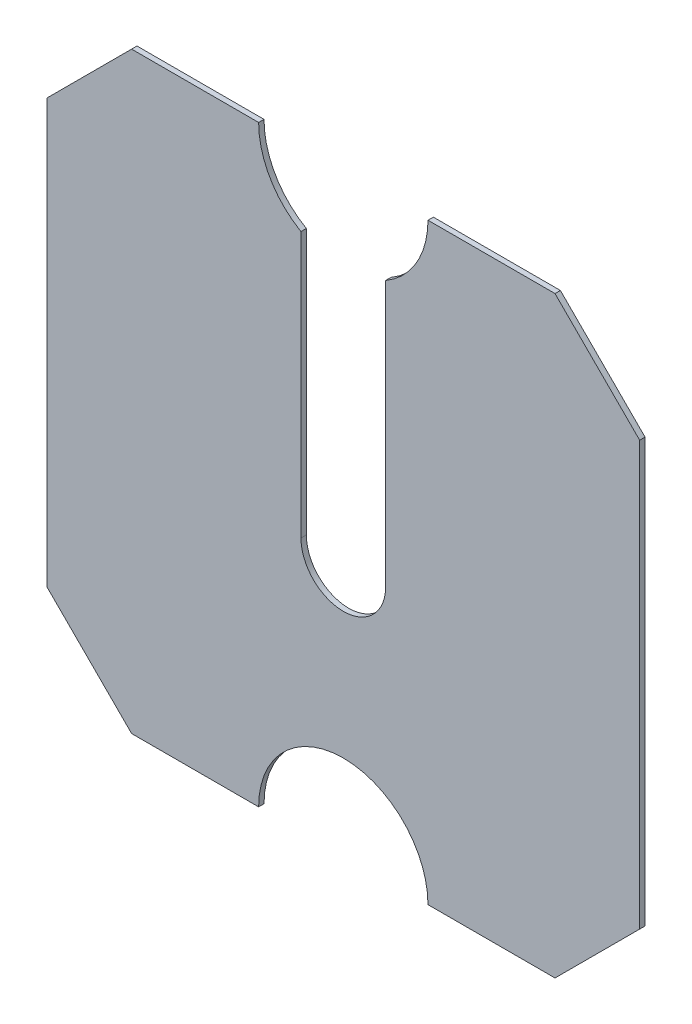
from build123d import *

# Parameters (mm, degrees)
BOSS_EXTRUDE1_DEPTH = 3.175
CUT_EXTRUDE1_DEPTH  = 3.175


with BuildPart() as part:
    # Sketch1 → Boss-Extrude1 (new body)
    with BuildSketch(Plane.XY):
        with BuildLine():
            Line((175, 300), (175, 50))
            Line((175, 50), (125, 0))
            Line((125, 0), (50, 0))
            ThreePointArc((50, 0), (0, 50), (-50, 0))
            Line((-50, 0), (-125, 0))
            Line((-125, 0), (-175, 50))
            Line((-175, 50), (-175, 300))
            Line((-175, 300), (-125, 350))
            Line((-125, 350), (-50, 350))
            ThreePointArc((-50, 350), (0, 300), (50, 350))
            Line((50, 350), (125, 350))
            Line((125, 350), (175, 300))
        make_face()
    extrude(amount=BOSS_EXTRUDE1_DEPTH)

    # Sketch2 → Cut-Extrude1 (cut)
    with BuildSketch(Plane.XY.offset(3.175)):
        with BuildLine():
            Line((-25, 306.698729811), (-25, 150))
            ThreePointArc((-25, 150), (0, 125), (25, 150))
            Line((25, 150), (25, 306.698729811))
            ThreePointArc((25, 306.698729811), (0, 300), (-25, 306.698729811))
        make_face()
    extrude(amount=-CUT_EXTRUDE1_DEPTH, mode=Mode.SUBTRACT)


solid = part.part
